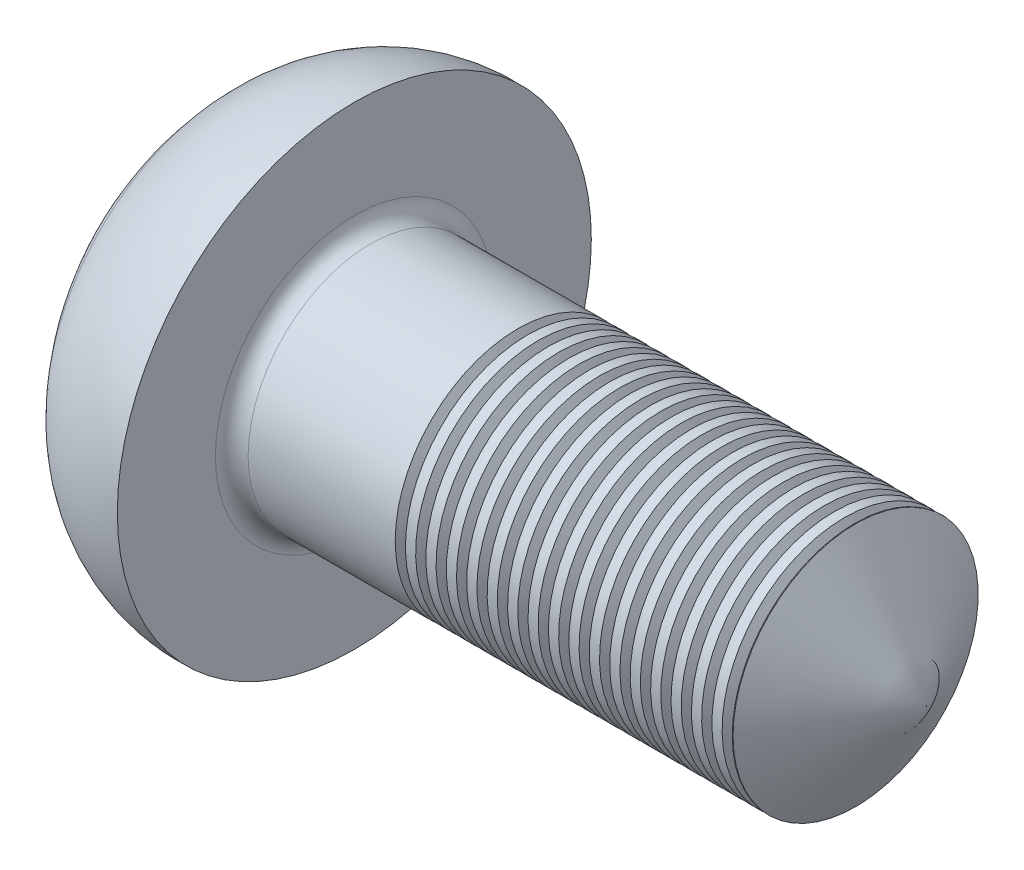
from build123d import *

# Parameters (mm, degrees)
FILLET2_R        = 0.2
LPATTERN10_COUNT = 20
LPATTERN10_PITCH = 0.25


with BuildPart() as part:
    # Sketch1 → Revolve1 (revolve)
    with BuildSketch(Plane(origin=(0, 0, 0), x_dir=(1, 0, 0), z_dir=(0, 1, 0))):
        with BuildLine():
            Line((2.37, 1.5), (9.37, 1.5))
            Line((9.37, 1.5), (9.37, 0))
            Line((9.37, 0), (0, 0))
            ThreePointArc((0, 0), (0.224879408, 1.215980768), (0.869770135, 2.271109163))
            ThreePointArc((0.869770135, 2.271109163), (1.549177667, 2.754228297), (2.37, 2.9))
            Line((2.37, 2.9), (2.37, 1.5))
        make_face()
    revolve(axis=Axis((-13.629268293, 0, 0), (1, 0, 0)))

    # Fillet2
    fillet2_edges = [part.edges().sort_by_distance(p)[0] for p in [
        (2.37, 0, 1.5),
    ]]
    fillet(fillet2_edges, radius=FILLET2_R)

    # Sketch4 → Cut-Revolve1 (revolve, cut)
    with BuildSketch(Plane(origin=(0, 0, 0), x_dir=(1, 0, 0), z_dir=(0, 1, 0))):
        Polygon((10.103454633, 0), (10.103454633, 21), (-2.754355653, 21), (9.37, 0), align=None)
    revolve(axis=Axis((4.782773752, 0, 0), (1, 0, 0)), mode=Mode.SUBTRACT)

    # Sketch2 → Cut-Loft1 section 0
    with BuildSketch(Plane(origin=(0, 0, 0), x_dir=(0, 0, -1), z_dir=(1, 0, 0)), mode=Mode.PRIVATE) as cut_loft1_s0:
        Polygon((-0.4625, 0.4625), (-1.85, 0.4625), (-1.85, -0.4625), (-0.4625, -0.4625), (-0.4625, -1.85), (0.4625, -1.85), (0.4625, -0.4625), (1.85, -0.4625), (1.85, 0.4625), (0.4625, 0.4625), (0.4625, 1.85), (-0.4625, 1.85), align=None)
    loft([Vertex(2.62, 0, 0), cut_loft1_s0.sketch], mode=Mode.SUBTRACT)

    # Sketch6 → Cut-Revolve10 (revolve, cut)
    with BuildSketch(Plane.XY):
        Polygon((4.37, 1.7), (4.495, 1.7), (4.495, 1.5), (4.4325, 1.391746825), (4.37, 1.5), align=None)
    cut_revolve10 = revolve(axis=Axis((10.774329131, 0, 0), (-1, 0, 0)), mode=Mode.SUBTRACT)

    # LPattern10: Cut-Revolve10 ×20
    with Locations(*[(i * LPATTERN10_PITCH, 0, 0) for i in range(1, LPATTERN10_COUNT)]):
        add(cut_revolve10, mode=Mode.SUBTRACT)


solid = part.part
